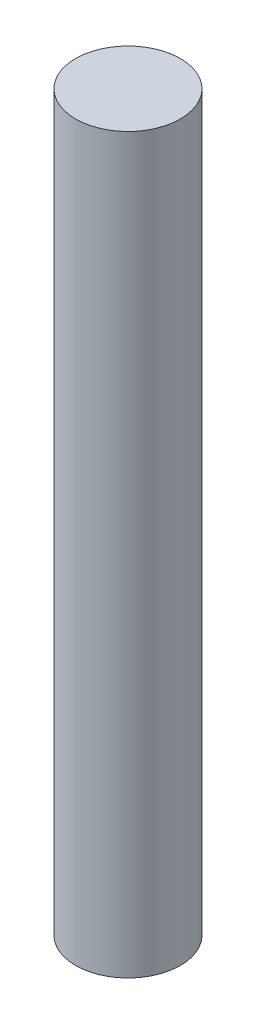
from build123d import *

# Parameters (mm, degrees)
SKETCH1_R           = 1.5875
BOSS_EXTRUDE1_DEPTH = 22.225


with BuildPart() as part:
    # Sketch1 → Boss-Extrude1 (new body)
    with BuildSketch(Plane(origin=(0, 0, 0), x_dir=(1, 0, 0), z_dir=(0, 1, 0))):
        Circle(SKETCH1_R)
    extrude(amount=BOSS_EXTRUDE1_DEPTH)


solid = part.part
